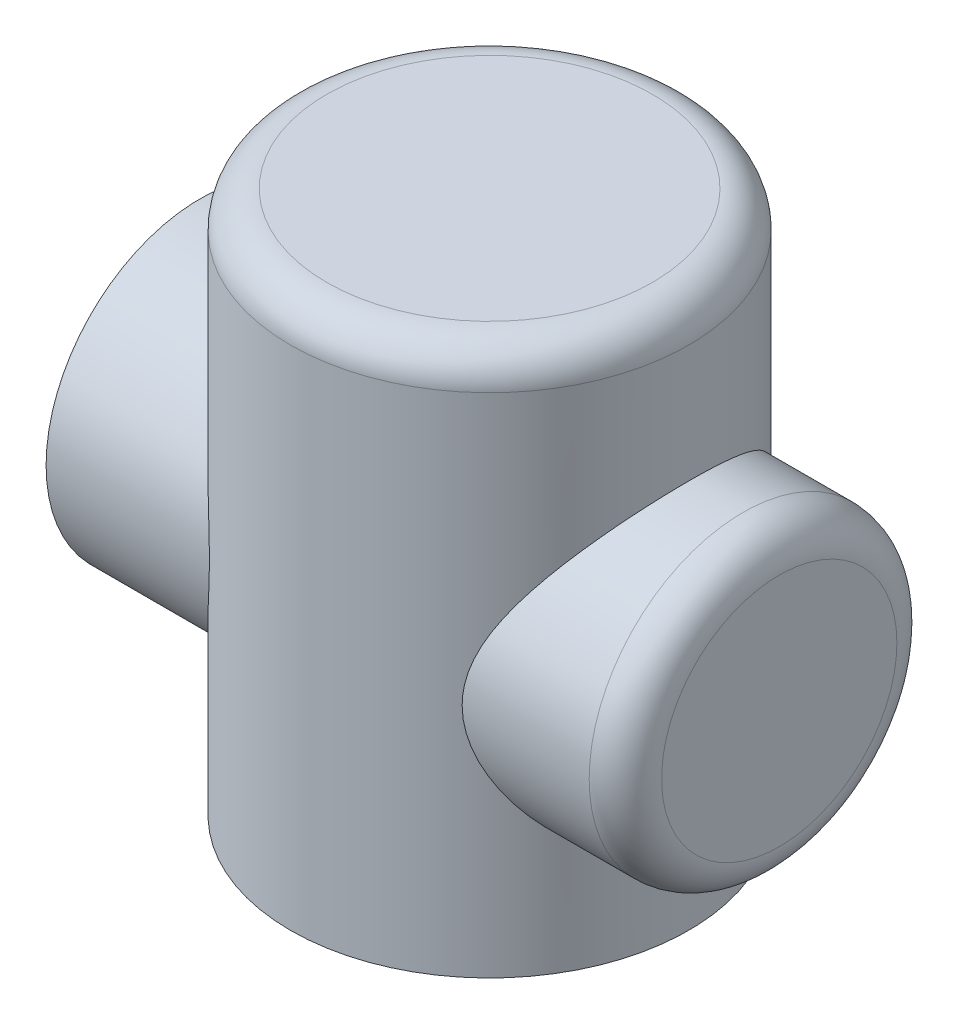
from build123d import *

# Parameters (mm, degrees)
SKETCH1_R               = 55
BOSS_EXTRUDE1_DEPTH     = 150
SKETCH11_R              = 42.5
CUT_EXTRUDE9_DEPTH      = 65
CUT_EXTRUDE9_DEPTH_BACK = 1
FILLET5_R               = 10
SKETCH3_R               = 42.5
BOSS_EXTRUDE6_DEPTH     = 80
FILLET7_R               = 10


with BuildPart() as part:
    # Sketch1 → Boss-Extrude1 (new body)
    with BuildSketch(Plane(origin=(0, 0, 0), x_dir=(1, 0, 0), z_dir=(0, 1, 0))):
        Circle(SKETCH1_R)
    extrude(amount=BOSS_EXTRUDE1_DEPTH)

    # Sketch11 → Cut-Extrude9 (cut, two sides)
    with BuildSketch(Plane(origin=(0, 0, 0), x_dir=(1, 0, 0), z_dir=(0, 1, 0))) as cut_extrude9_sk:
        Circle(SKETCH11_R)
    extrude(amount=CUT_EXTRUDE9_DEPTH, mode=Mode.SUBTRACT)
    extrude(cut_extrude9_sk.sketch, amount=-CUT_EXTRUDE9_DEPTH_BACK, mode=Mode.SUBTRACT)

    # Fillet5
    fillet5_edges = [part.edges().sort_by_distance(p)[0] for p in [
        (-55, 150, 0),
    ]]
    fillet(fillet5_edges, radius=FILLET5_R)

    # Sketch3 → Boss-Extrude6 (add, symmetric)
    with BuildSketch(Plane(origin=(0, 0, 0), x_dir=(0, 0, -1), z_dir=(1, 0, 0))):
        with Locations((0, 65)):
            Circle(SKETCH3_R)
    extrude(amount=BOSS_EXTRUDE6_DEPTH, both=True)

    # Fillet7
    fillet7_edges = [part.edges().sort_by_distance(p)[0] for p in [
        (80, 65, 42.5),
    ]]
    fillet(fillet7_edges, radius=FILLET7_R)


solid = part.part
